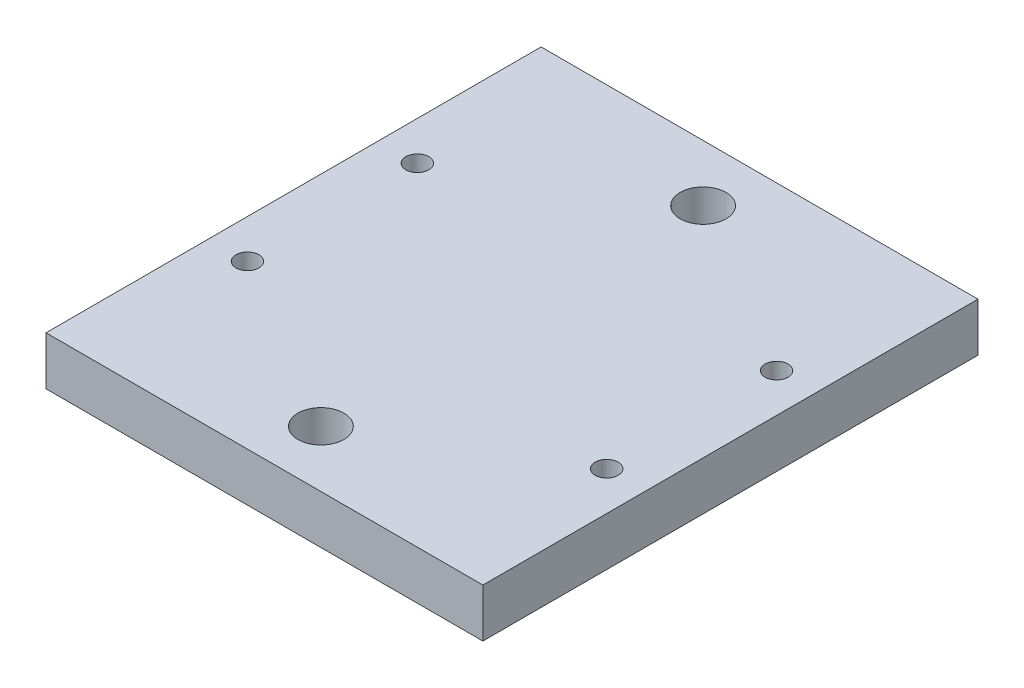
from build123d import *

# Parameters (mm, degrees)
SKETCH1_W           = 57.15
SKETCH1_H           = 64.77
SKETCH1_R           = 1.5
SKETCH1_R_2         = 3
BOSS_EXTRUDE1_DEPTH = 6.35


with BuildPart() as part:
    # Sketch1 → Boss-Extrude1 (new body)
    with BuildSketch(Plane(origin=(0, 0, 0), x_dir=(1, 0, 0), z_dir=(0, 1, 0))):
        with Locations((28.575, 32.385)):
            Rectangle(SKETCH1_W, SKETCH1_H)
        with Locations((5.08, 21.2725)):
            Circle(SKETCH1_R, mode=Mode.SUBTRACT)
        with Locations((5.08, 43.4975)):
            Circle(SKETCH1_R, mode=Mode.SUBTRACT)
        with Locations((52.07, 21.2725)):
            Circle(SKETCH1_R, mode=Mode.SUBTRACT)
        with Locations((52.07, 43.4975)):
            Circle(SKETCH1_R, mode=Mode.SUBTRACT)
        with Locations((28.575, 7.385)):
            Circle(SKETCH1_R_2, mode=Mode.SUBTRACT)
        with Locations((28.575, 57.385)):
            Circle(SKETCH1_R_2, mode=Mode.SUBTRACT)
    extrude(amount=BOSS_EXTRUDE1_DEPTH)


solid = part.part
